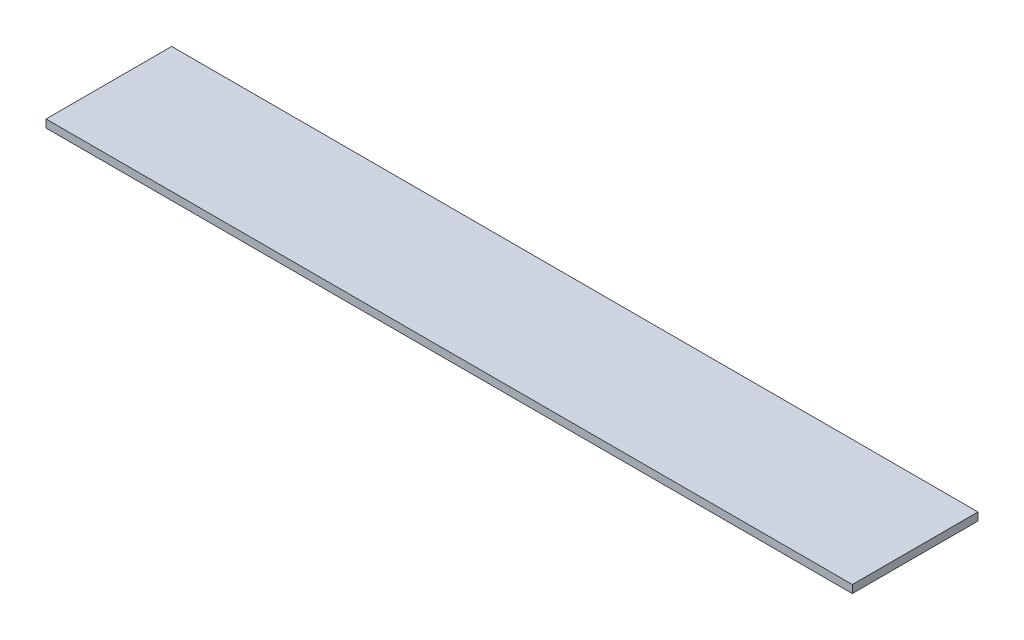
from build123d import *

# Parameters (mm, degrees)
CROQUIS1_W              = 308
CROQUIS1_H              = 48
SALIENTE_EXTRUIR1_DEPTH = 3


with BuildPart() as part:
    # Croquis1 → Saliente-Extruir1 (new body)
    with BuildSketch(Plane(origin=(0, 0, 0), x_dir=(1, 0, 0), z_dir=(0, 1, 0))):
        with Locations((154, 24)):
            Rectangle(CROQUIS1_W, CROQUIS1_H)
    extrude(amount=SALIENTE_EXTRUIR1_DEPTH)


solid = part.part
